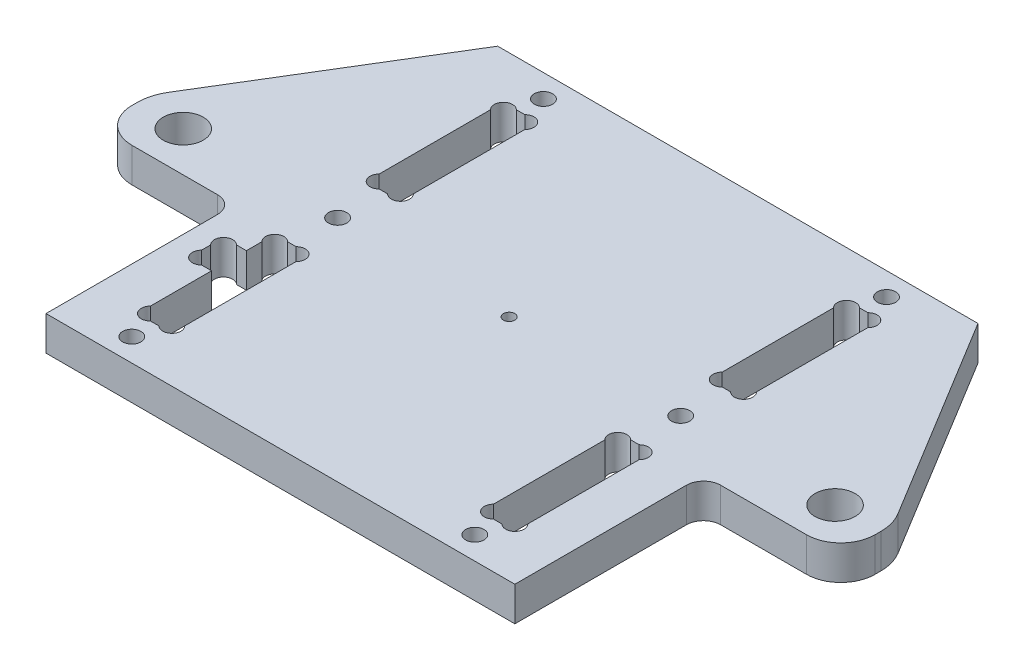
from build123d import *

# Parameters (mm, degrees)
ESQUISSE1_R      = 1.6
ESQUISSE1_R_2    = 3.5
ESQUISSE1_R_3    = 1
EXTRUSION1_DEPTH = 6


with BuildPart() as part:
    # Esquisse1 → Extrusion1 (new body)
    with BuildSketch(Plane(origin=(0, 0, 0), x_dir=(1, 0, 0), z_dir=(0, 1, 0))):
        with BuildLine():
            Line((42, 80), (63.832091269, 44.162034226))
            ThreePointArc((63.832091269, 44.162034226), (64.702490836, 42.161396522), (65, 40))
            Line((65, 40), (65, 39))
            ThreePointArc((65, 39), (63.242640687, 34.757359313), (59, 33))
            Line((59, 33), (44, 33))
            ThreePointArc((44, 33), (41.878679656, 32.121320344), (41, 30))
            Line((41, 30), (41, 0))
            Line((41, 0), (-41, 0))
            Line((-41, 0), (-41, 30))
            ThreePointArc((-41, 30), (-41.878679656, 32.121320344), (-44, 33))
            Line((-44, 33), (-59, 33))
            ThreePointArc((-59, 33), (-63.242640687, 34.757359313), (-65, 39))
            Line((-65, 39), (-65, 40))
            ThreePointArc((-65, 40), (-64.702490836, 42.161396522), (-63.832091269, 44.162034226))
            Line((-63.832091269, 44.162034226), (-42, 80))
            Line((-42, 80), (42, 80))
        make_face()
        with Locations(Location((-30, 4, 0), (0, 0, 270))):  # turned: the seam where the file's is
            Circle(ESQUISSE1_R, mode=Mode.SUBTRACT)
        with Locations(Location((-30, 76, 0), (0, 0, 90))):  # turned: the seam where the file's is
            Circle(ESQUISSE1_R, mode=Mode.SUBTRACT)
        with Locations(Location((-30, 40, 0), (0, 0, 270))):  # turned: the seam where the file's is
            Circle(ESQUISSE1_R, mode=Mode.SUBTRACT)
        with Locations(Location((57, 40, 0), (0, 0, 90))):  # turned: the seam where the file's is
            Circle(ESQUISSE1_R_2, mode=Mode.SUBTRACT)
        with Locations(Location((30, 4, 0), (0, 0, 90))):  # turned: the seam where the file's is
            Circle(ESQUISSE1_R, mode=Mode.SUBTRACT)
        with Locations(Location((30, 40, 0), (0, 0, 90))):  # turned: the seam where the file's is
            Circle(ESQUISSE1_R, mode=Mode.SUBTRACT)
        with Locations(Location((-57, 40, 0), (0, 0, 270))):  # turned: the seam where the file's is
            Circle(ESQUISSE1_R_2, mode=Mode.SUBTRACT)
        with Locations(Location((30, 76, 0), (0, 0, 270))):  # turned: the seam where the file's is
            Circle(ESQUISSE1_R, mode=Mode.SUBTRACT)
        with Locations(Location((0, 40, 0), (0, 0, 270))):  # turned: the seam where the file's is
            Circle(ESQUISSE1_R_3, mode=Mode.SUBTRACT)
        with BuildLine():
            Line((-33, 50.2627417), (-33, 69.7372583))
            ThreePointArc((-33, 69.7372583), (-33, 72), (-30.7372583, 72))
            Line((-30.7372583, 72), (-29.2627417, 72))
            ThreePointArc((-29.2627417, 72), (-27, 72), (-27, 69.7372583))
            Line((-27, 69.7372583), (-27, 50.2627417))
            ThreePointArc((-27, 50.2627417), (-27, 48), (-29.2627417, 48))
            Line((-29.2627417, 48), (-30.7372583, 48))
            ThreePointArc((-30.7372583, 48), (-33, 48), (-33, 50.2627417))
        make_face(mode=Mode.SUBTRACT)
        with BuildLine():
            Line((-30.7372583, 32), (-29.2627417, 32))
            ThreePointArc((-29.2627417, 32), (-27, 32), (-27, 29.7372583))
            Line((-27, 29.7372583), (-27, 10.2627417))
            ThreePointArc((-27, 10.2627417), (-27, 8), (-29.2627417, 8))
            Line((-29.2627417, 8), (-30.7372583, 8))
            ThreePointArc((-30.7372583, 8), (-33, 8), (-33, 10.2627417))
            Line((-33, 10.2627417), (-33, 20.95))
            Line((-33, 20.95), (-34.7372583, 20.95))
            ThreePointArc((-34.7372583, 20.95), (-37, 20.95), (-37, 23.2127417))
            Line((-37, 23.2127417), (-37, 24.7872583))
            ThreePointArc((-37, 24.7872583), (-37, 27.05), (-34.7372583, 27.05))
            Line((-34.7372583, 27.05), (-33, 27.05))
            Line((-33, 27.05), (-33, 29.7372583))
            ThreePointArc((-33, 29.7372583), (-33, 32), (-30.7372583, 32))
        make_face(mode=Mode.SUBTRACT)
        with BuildLine():
            Line((30.7372583, 72), (29.2627417, 72))
            ThreePointArc((29.2627417, 72), (27, 72), (27, 69.7372583))
            Line((27, 69.7372583), (27, 50.2627417))
            ThreePointArc((27, 50.2627417), (27, 48), (29.2627417, 48))
            Line((29.2627417, 48), (30.7372583, 48))
            ThreePointArc((30.7372583, 48), (33, 48), (33, 50.2627417))
            Line((33, 50.2627417), (33, 69.7372583))
            ThreePointArc((33, 69.7372583), (33, 72), (30.7372583, 72))
        make_face(mode=Mode.SUBTRACT)
        with BuildLine():
            Line((27, 29.7372583), (27, 10.2627417))
            ThreePointArc((27, 10.2627417), (27, 8), (29.2627417, 8))
            Line((29.2627417, 8), (30.7372583, 8))
            ThreePointArc((30.7372583, 8), (33, 8), (33, 10.2627417))
            Line((33, 10.2627417), (33, 29.7372583))
            ThreePointArc((33, 29.7372583), (33, 32), (30.7372583, 32))
            Line((30.7372583, 32), (29.2627417, 32))
            ThreePointArc((29.2627417, 32), (27, 32), (27, 29.7372583))
        make_face(mode=Mode.SUBTRACT)
    extrude(amount=EXTRUSION1_DEPTH)


solid = part.part
